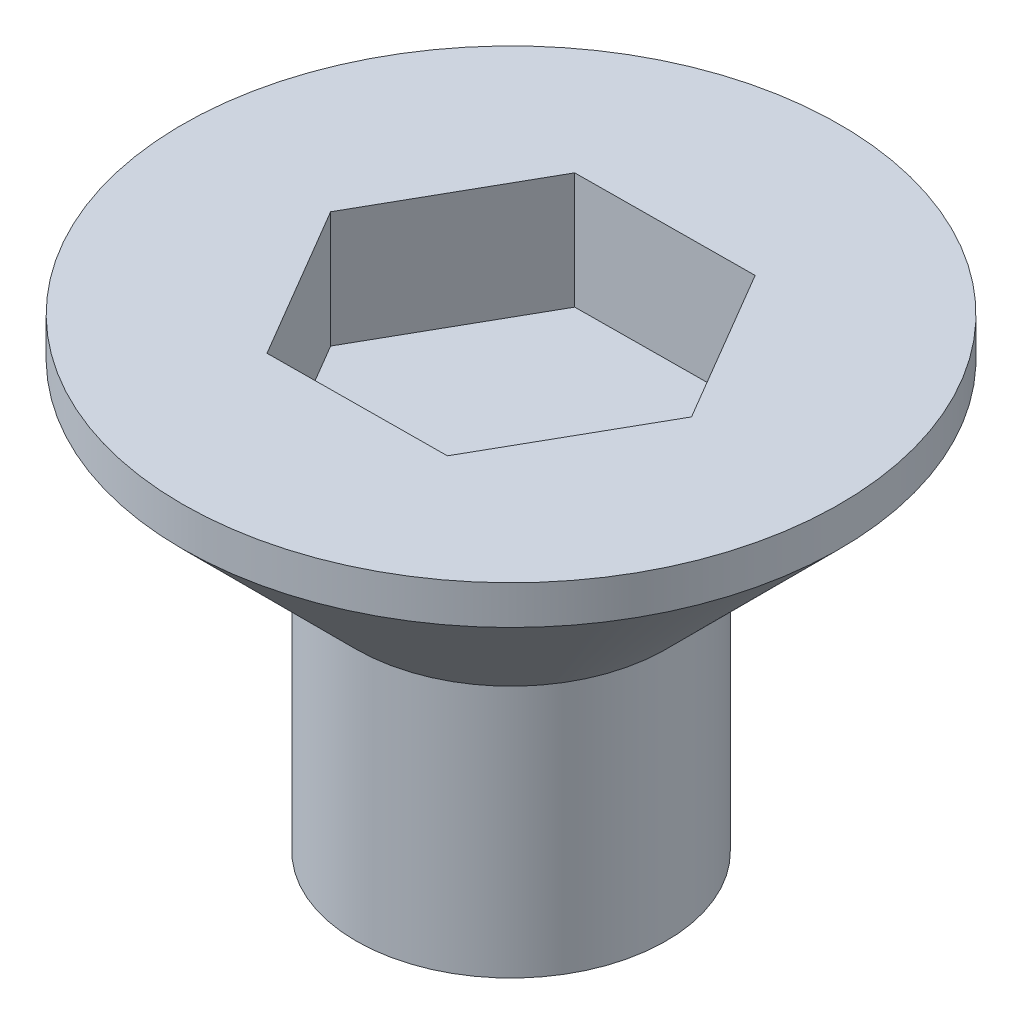
from build123d import *

# Parameters (mm, degrees)
CUT_EXTRUDE_1_DEPTH = 3


with BuildPart() as part:
    # Эскиз1 → Повернуть1 (revolve)
    with BuildSketch(Plane.XY):
        Polygon((0, 0), (4, 0), (4, 6.519431445), (8.480568555, 11), (8.480568555, 12), (0, 12), align=None)
    revolve(axis=Axis((0, 68.644575989, 0), (0, -1, 0)))

    # Эскиз2 → Вырез-Вытянуть1 (cut)
    with BuildSketch(Plane(origin=(0, 12, 0), x_dir=(1, 0, 0), z_dir=(0, 1, 0))):
        Polygon((2.340353871, -3.981968997), (4.618663244, 0.035821408), (2.278309373, 4.017790405), (-2.340353871, 3.981968997), (-4.618663244, -0.035821408), (-2.278309373, -4.017790405), align=None)
    extrude(amount=-CUT_EXTRUDE_1_DEPTH, mode=Mode.SUBTRACT)


solid = part.part
